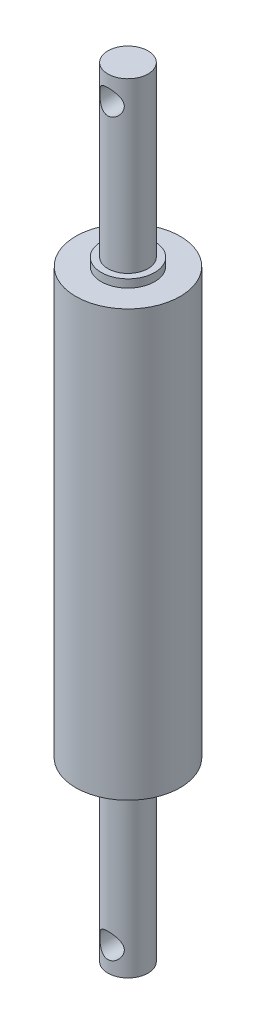
from build123d import *

# Parameters (mm, degrees)
BOSS_EXTRUDE1_DEPTH      = 53
BOSS_EXTRUDE1_DEPTH_BACK = 53
SKETCH1_R                = 13
SKETCH2_R                = 6.65
BOSS_EXTRUDE2_DEPTH      = 2
SKETCH3_R                = 5
BOSS_EXTRUDE3_DEPTH      = 42
SKETCH4_R                = 3.05
CUT_EXTRUDE1_DEPTH       = 99.726896031


with BuildPart() as part:
    # Sketch1 → Boss-Extrude1 (new, two sides: drawn at the far end of the back side and taken through both)
    with BuildSketch(Plane(origin=(0, 0, 0), x_dir=(1, 0, 0), z_dir=(0, 1, 0)).offset(-BOSS_EXTRUDE1_DEPTH_BACK)):
        Circle(SKETCH1_R)
    extrude(amount=BOSS_EXTRUDE1_DEPTH + BOSS_EXTRUDE1_DEPTH_BACK)

    # Sketch2 → Boss-Extrude2 (add)
    with BuildSketch(Plane(origin=(0, 53, 0), x_dir=(1, 0, 0), z_dir=(0, 1, 0))):
        Circle(SKETCH2_R)
    boss_extrude2 = extrude(amount=BOSS_EXTRUDE2_DEPTH)

    # Sketch3 → Boss-Extrude3 (add)
    with BuildSketch(Plane(origin=(0, 55, 0), x_dir=(1, 0, 0), z_dir=(0, 1, 0))):
        Circle(SKETCH3_R)
    boss_extrude3 = extrude(amount=BOSS_EXTRUDE3_DEPTH)

    # Mirror1: Boss-Extrude2, Boss-Extrude3 across plane
    add(boss_extrude2.mirror(Plane.ZX))
    add(boss_extrude3.mirror(Plane.ZX))

    # Sketch4 → Cut-Extrude1 (cut, symmetric)
    with BuildSketch(Plane.XY):
        with Locations((0, 91)):
            Circle(SKETCH4_R)
    cut_extrude1 = extrude(amount=CUT_EXTRUDE1_DEPTH, both=True, mode=Mode.SUBTRACT)

    # Mirror2: Cut-Extrude1 across plane
    add(cut_extrude1.mirror(Plane.ZX), mode=Mode.SUBTRACT)


solid = part.part
